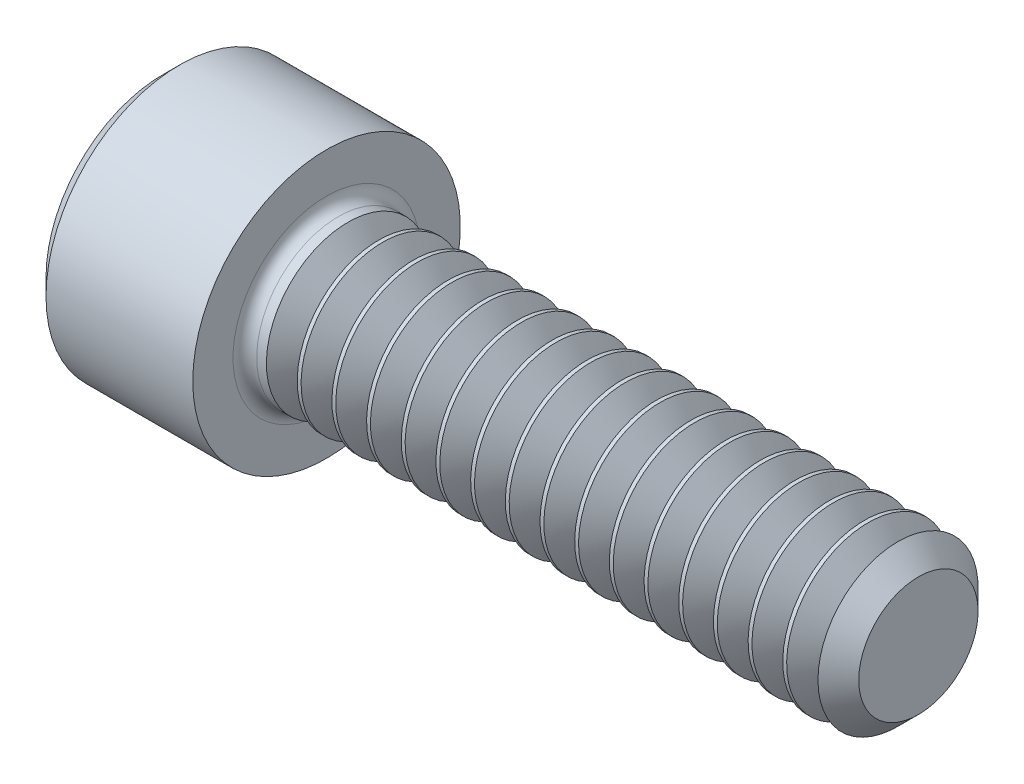
from build123d import *

# Parameters (mm, degrees)
FILLET1_R       = 0.254
HEX_2_DEPTH     = 1.6256
THDSCHPAT_COUNT = 16
THDSCHPAT_PITCH = 0.74422


with BuildPart() as part:
    # BodySke → Base-Revolve (revolve)
    with BuildSketch(Plane.XY):
        Polygon((0, 0), (0, 2.5146), (0.3556, 2.8702), (3.5052, 2.8702), (3.5052, 1.7526), (15.73276, 1.7526), (16.2052, 1.28016), (16.2052, 0), align=None)
    revolve(axis=Axis((-31.75, 0, 0), (1, 0, 0)))

    # Fillet1
    fillet1_edges = [part.edges().sort_by_distance(p)[0] for p in [
        (3.5052, -1.7526, 0),
    ]]
    fillet(fillet1_edges, radius=FILLET1_R)

    # Sketch2 → Hex-PreBroach (revolve, cut)
    with BuildSketch(Plane.XY):
        Polygon((0, 1.3843), (1.6256, 1.3843), (2.424825978, 0), (0, 0), align=None)
    revolve(axis=Axis((0, 0, 0), (1, 0, 0)), mode=Mode.SUBTRACT)

    # Sketch3 → Hex 2 (cut)
    with BuildSketch(Plane(origin=(0, 0, 0), x_dir=(0, 0.5, 0.866025404), z_dir=(-1, 0, 0))):
        Polygon((0.799225978, 1.3843), (-0.799225978, 1.3843), (-1.598451955, 0), (-0.799225978, -1.3843), (0.799225978, -1.3843), (1.598451955, 0), align=None)
    extrude(amount=-HEX_2_DEPTH, mode=Mode.SUBTRACT)

    # ThdSchSke → ThreadSchematic (revolve, cut)
    with BuildSketch(Plane.XY):
        Polygon((4.29768, -1.28016), (3.966873951, -1.7526), (3.966873951, -2.19075), (4.628486049, -2.19075), (4.628486049, -1.7526), align=None)
    threadschematic = revolve(axis=Axis((-3.175, 0, 0), (1, 0, 0)), mode=Mode.SUBTRACT)

    # ThdSchPat: ThreadSchematic ×16
    with Locations(*[(i * THDSCHPAT_PITCH, 0, 0) for i in range(1, THDSCHPAT_COUNT)]):
        add(threadschematic, mode=Mode.SUBTRACT)


solid = part.part
